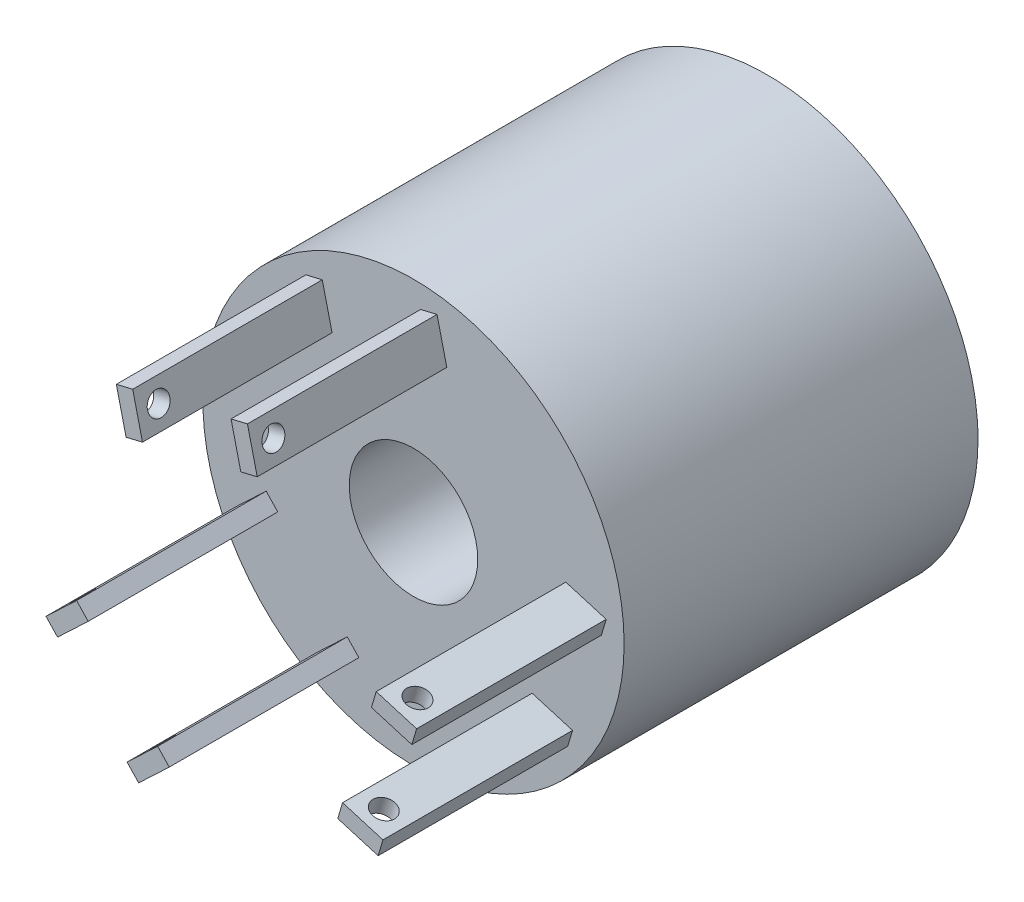
from build123d import *
from build123d.topology import SkipClean

# Parameters (mm, degrees)
SKETCH1_R               = 50
SKETCH3_R               = 50
BOSS_EXTRUDE1_DEPTH     = 45
SKETCH21_R              = 15.25
CUT_EXTRUDE1_DEPTH      = 115.45523151
CUT_EXTRUDE1_DEPTH_BACK = 115.45523151
SKETCH23_W              = 2.65
SKETCH23_H              = 49.393967623
M5_CLEARANCE_HOLE8_D    = 5.3
SKETCH27_W              = 2.65
SKETCH27_H              = 60.041961507
M5_CLEARANCE_HOLE10_D   = 5.3
SKETCH32_W              = 2.65
SKETCH32_H              = 51.511335507
M5_CLEARANCE_HOLE12_D   = 5.3
SKETCH35_R              = 50
BOSS_EXTRUDE2_DEPTH     = 39
SKETCH36_R              = 5
BOSS_EXTRUDE3_DEPTH     = 10
CHAMFER1_SIZE           = 2


with BuildPart() as part:
    # Sketch1 → Loft1 section 0
    with BuildSketch(Plane.XY):
        Circle(SKETCH1_R)
    # Sketch3 → Loft1 section 1
    with BuildSketch(Plane.XY.offset(45)):
        Circle(SKETCH3_R)
    loft()

    # Sketch4 → Boss-Extrude1 (add)
    with BuildSketch(Plane.XY.offset(45)):
        Polygon((-21.649255971, 39.042410979), (-25.54010328, 38.114344591), (-23.21993731, 28.387226319), (-19.329090001, 29.315292707), align=None)
        Polygon((1.695827881, 44.610809306), (5.58667519, 45.538875693), (7.90684116, 35.811757422), (4.015993851, 34.883691034), align=None)
        Polygon((35.016664181, 1.962066431), (36.158358767, 5.795672237), (45.74237328, 2.941435772), (44.600678694, -0.892170034), align=None)
        Polygon((28.166496664, -21.039568402), (27.024802078, -24.873174207), (36.608816592, -27.727410673), (37.750511178, -23.893804867), align=None)
        Polygon((-22.987090484, -38.270012468), (-20.237937762, -41.175551885), (-12.974089217, -34.302670079), (-15.72324194, -31.397130661), align=None)
        Polygon((-39.48200682, -20.836775962), (-42.231159542, -17.931236544), (-34.967310998, -11.058354737), (-32.218158276, -13.963894155), align=None)
    extrude(amount=BOSS_EXTRUDE1_DEPTH)

    # Sketch21 → Cut-Extrude1 (cut, two sides)
    with BuildSketch(Plane(origin=(0, 0, 0), x_dir=(-1, 0, 0), z_dir=(0, 0, -1))) as cut_extrude1_sk:
        Circle(SKETCH21_R)
    extrude(amount=CUT_EXTRUDE1_DEPTH, mode=Mode.SUBTRACT)
    extrude(cut_extrude1_sk.sketch, amount=-CUT_EXTRUDE1_DEPTH_BACK, mode=Mode.SUBTRACT)

    # Sketch23 → M5 Clearance Hole7 (revolve, cut)
    with BuildSketch(Plane(origin=(2.855910866, 39.74725017, 85), x_dir=(0.23201659695614316, -0.9727118271805328, 0), z_dir=(0, 0, 1))):
        with Locations((1.325, 24.696983812)):
            Rectangle(SKETCH23_W, SKETCH23_H)
    revolve(axis=Axis((-3.320809236, 38.273944779, 85), (0.9727118271805328, 0.23201659695614313, 0)), mode=Mode.SUBTRACT)

    # M5 Clearance Hole8 (through all)
    with Locations(Plane(origin=(-11.672541926, -2.784199164, 0), x_dir=(0, 0, -1), z_dir=(0.9727118271805437, 0.23201659695609775, 0))):
        with Locations((-85, 38.000001617)):
            Hole(M5_CLEARANCE_HOLE8_D / 2)

    # Sketch27 → M5 Clearance Hole9 (revolve, cut)
    with BuildSketch(Plane(origin=(-35.850082548, -17.400335058, 85), x_dir=(0.7263848544218454, 0.687288180653905, 0), z_dir=(0, 0, 1))):
        with Locations((1.325, 30.020980754)):
            Rectangle(SKETCH27_W, SKETCH27_H)
    revolve(axis=Axis((-31.485802601, -22.012878884, 85), (-0.6872881806539048, 0.7263848544218454, 0)), mode=Mode.SUBTRACT)

    # M5 Clearance Hole10 (through all)
    with Locations(Plane(origin=(8.247459431, -8.716619588, 0), x_dir=(0.726384854421872, 0.6872881806538769, 0), z_dir=(-0.6872881806538769, 0.726384854421872, 0))):
        with Locations((-38.000001617, -85)):
            Hole(M5_CLEARANCE_HOLE10_D / 2)

    # Sketch32 → M5 Clearance Hole11 (revolve, cut)
    with BuildSketch(Plane(origin=(39.808671437, 0.534948199, 85), x_dir=(0.9584014513779905, -0.28542364652663516, 0), z_dir=(0, 0, 1))):
        with Locations((1.325, 25.755667754)):
            Rectangle(SKETCH32_W, SKETCH32_H)
    revolve(axis=Axis((37.996231282, -5.550901018, 85), (0.2854236465266351, 0.9584014513779905, 0)), mode=Mode.SUBTRACT)

    # M5 Clearance Hole12 (through all)
    with Locations(Plane(origin=(-3.460752782, -11.620587605, 0), x_dir=(0.9584014513779878, -0.28542364652664387, 0), z_dir=(0.28542364652664387, 0.9584014513779878, 0))):
        with Locations((38.000001617, -85)):
            Hole(M5_CLEARANCE_HOLE12_D / 2)

    # Sketch35 → Boss-Extrude2 (add)
    with SkipClean():  # the faces are left unmerged after this step: merging them gives an invalid solid
        with BuildSketch(Plane(origin=(0, 0, 0), x_dir=(-1, 0, 0), z_dir=(0, 0, -1))):
            with Locations(Location((0, 0, 0), (0, 0, 180))):
                Circle(SKETCH35_R)
            with BuildLine():
                ThreePointArc((-4.1, 15.35), (-4.448683298, 16.466227766), (-3.5, 17.15))
                Line((-3.5, 17.15), (3.5, 17.15))
                ThreePointArc((3.5, 17.15), (4.448683298, 16.466227766), (4.1, 15.35))
                ThreePointArc((4.1, 15.35), (5, 12.65), (5.9, 15.35))
                ThreePointArc((5.9, 15.35), (5.551316702, 16.466227766), (6.5, 17.15))
                Line((6.5, 17.15), (10.5, 17.15))
                Line((10.5, 17.15), (10.5, 11.05949818))
                ThreePointArc((10.5, 11.05949818), (15.25, 0), (10.5, -11.05949818))
                Line((10.5, -11.05949818), (10.5, -37.15))
                Line((10.5, -37.15), (-10.5, -37.15))
                Line((-10.5, -37.15), (-10.5, -11.05949818))
                ThreePointArc((-10.5, -11.05949818), (-15.25, 0), (-10.5, 11.05949818))
                Line((-10.5, 11.05949818), (-10.5, 17.15))
                Line((-10.5, 17.15), (-6.5, 17.15))
                ThreePointArc((-6.5, 17.15), (-5.551316702, 16.466227766), (-5.9, 15.35))
                ThreePointArc((-5.9, 15.35), (-5, 12.65), (-4.1, 15.35))
            make_face(mode=Mode.SUBTRACT)
        extrude(amount=BOSS_EXTRUDE2_DEPTH)

    # Sketch36 → Boss-Extrude3 (add)
    with SkipClean():  # the faces are left unmerged after this step: merging them gives an invalid solid
        with BuildSketch(Plane(origin=(0, 0, -39), x_dir=(-1, 0, 0), z_dir=(0, 0, -1))):
            with Locations((0, 30)):
                Circle(SKETCH36_R)
            with Locations((-30, 0)):
                Circle(SKETCH36_R)
            with Locations((30, 0)):
                Circle(SKETCH36_R)
        extrude(amount=BOSS_EXTRUDE3_DEPTH)

    # Chamfer1
    chamfer1_edges = [part.edges().sort_by_distance(p)[0] for p in [
        (5, 30, -49),
        (35, 0, -49),
        (-25, 0, -49),
    ]]
    chamfer(chamfer1_edges, length=CHAMFER1_SIZE)


solid = part.part
